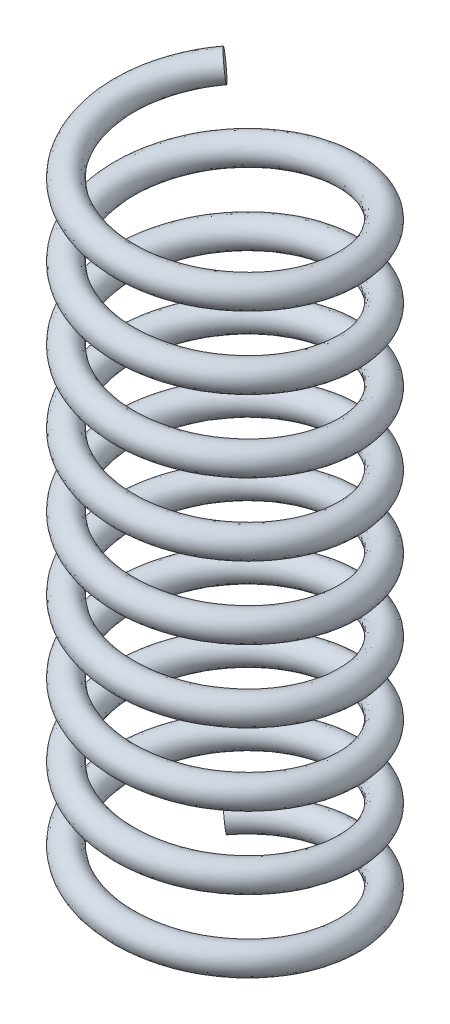
from build123d import *

# Parameters (mm, degrees)
SWEEP_1_PITCH       = 1.7
SWEEP_1_HEIGHT      = 15.3
SWEEP_1_RADIUS      = 2.65
SWEEP_1_START_ANGLE = -135
SKETCH_2_R          = 0.325


with BuildPart() as part:
    # 扫描1: sweep along a helix
    with BuildLine() as sweep_1_path:
        add(Helix(SWEEP_1_PITCH, SWEEP_1_HEIGHT, SWEEP_1_RADIUS, center=(0, 0, 0), direction=(0, 1, 0), lefthand=True, mode=Mode.PRIVATE).rotate(Axis((0, 0, 0), (0, 1, 0)), SWEEP_1_START_ANGLE))
    # 草图2 → 扫描1 (sweep)
    with BuildSketch(Plane(origin=(-1.87383297, 0, -1.87383297), x_dir=(-0.710744941, 0.10052883, -0.696229548), z_dir=(0.703449806, 0.101571365, -0.703449806))):
        with Locations((-2.5744e-05, 0.003745592)):
            Circle(SKETCH_2_R)
    sweep(path=sweep_1_path.line, is_frenet=True)


solid = part.part
